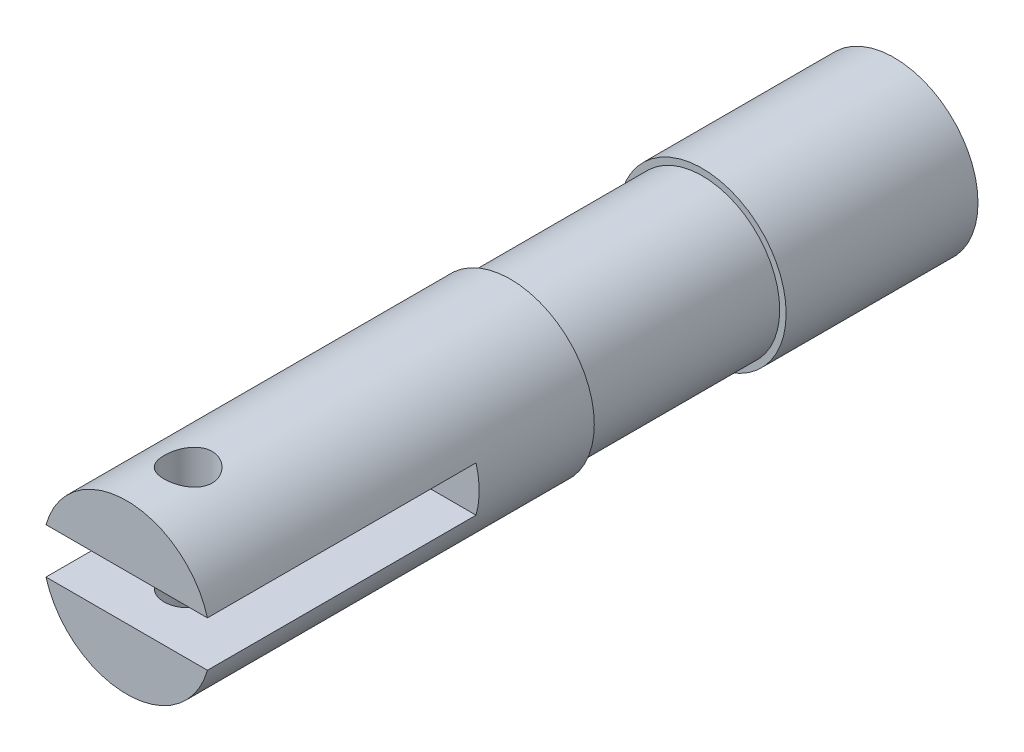
from build123d import *

# Parameters (mm, degrees)
SKETCH1_R               = 5.5499
BOSS_EXTRUDE1_DEPTH     = 38.1
CUT_EXTRUDE1_DEPTH      = 17.78
SKETCH3_R               = 1.5875
CUT_EXTRUDE2_DEPTH      = 8.0499
CUT_EXTRUDE2_DEPTH_BACK = 5.0499
SKETCH4_R               = 5.5499
BOSS_EXTRUDE4_DEPTH     = 12.7
SKETCH6_R               = 5.5499
SKETCH6_R_2             = 5.12385248
CUT_EXTRUDE4_DEPTH      = 12.7


with BuildPart() as part:
    # Sketch1 → Boss-Extrude1 (new body)
    with BuildSketch(Plane.XY):
        Circle(SKETCH1_R)
    extrude(amount=BOSS_EXTRUDE1_DEPTH)

    # Sketch2 → Cut-Extrude1 (cut)
    with BuildSketch(Plane.XY.offset(38.1)):
        with BuildLine():
            Line((5.343350074, 1.5), (-5.343350074, 1.5))
            ThreePointArc((-5.343350074, 1.5), (-5.5499, 0), (-5.343350074, -1.5))
            Line((-5.343350074, -1.5), (5.343350074, -1.5))
            ThreePointArc((5.343350074, -1.5), (5.5499, 0), (5.343350074, 1.5))
        make_face()
    extrude(amount=-CUT_EXTRUDE1_DEPTH, mode=Mode.SUBTRACT)

    # Sketch3 → Cut-Extrude2 (cut, two sides)
    with BuildSketch(Plane(origin=(0, -1.5, 0), x_dir=(1, 0, 0), z_dir=(0, 1, 0))) as cut_extrude2_sk:
        with Locations((0, -34.036)):
            Circle(SKETCH3_R)
    extrude(amount=CUT_EXTRUDE2_DEPTH, mode=Mode.SUBTRACT)
    extrude(cut_extrude2_sk.sketch, amount=-CUT_EXTRUDE2_DEPTH_BACK, mode=Mode.SUBTRACT)

    # Sketch4 → Boss-Extrude4 (add)
    with BuildSketch(Plane.XY):
        Circle(SKETCH4_R)
    extrude(amount=-BOSS_EXTRUDE4_DEPTH)

    # Sketch6 → Cut-Extrude4 (cut)
    with BuildSketch(Plane.XY):
        Circle(SKETCH6_R)
        Circle(SKETCH6_R_2, mode=Mode.SUBTRACT)
    extrude(amount=CUT_EXTRUDE4_DEPTH, mode=Mode.SUBTRACT)


solid = part.part
